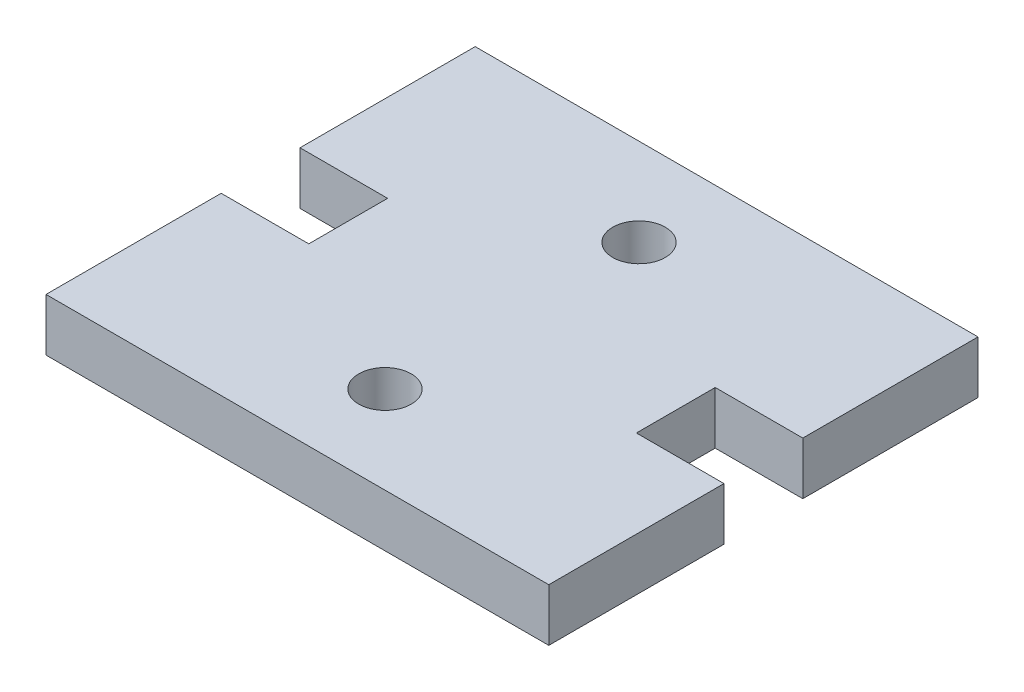
from build123d import *

# Parameters (mm, degrees)
SKETCH1_R           = 1.5
BOSS_EXTRUDE1_DEPTH = 3


with BuildPart() as part:
    # Sketch1 → Boss-Extrude1 (new body)
    with BuildSketch(Plane(origin=(0, 0, 0), x_dir=(1, 0, 0), z_dir=(0, 1, 0))):
        Polygon((-14.35, 2.25), (-14.35, 12.25), (14.35, 12.25), (14.35, 2.25), (9.35, 2.25), (9.35, -2.25), (14.35, -2.25), (14.35, -12.25), (-14.35, -12.25), (-14.35, -2.25), (-9.35, -2.25), (-9.35, 2.25), align=None)
        with Locations((0, 7.25)):
            Circle(SKETCH1_R, mode=Mode.SUBTRACT)
        with Locations((0, -7.25)):
            Circle(SKETCH1_R, mode=Mode.SUBTRACT)
    extrude(amount=BOSS_EXTRUDE1_DEPTH)


solid = part.part
